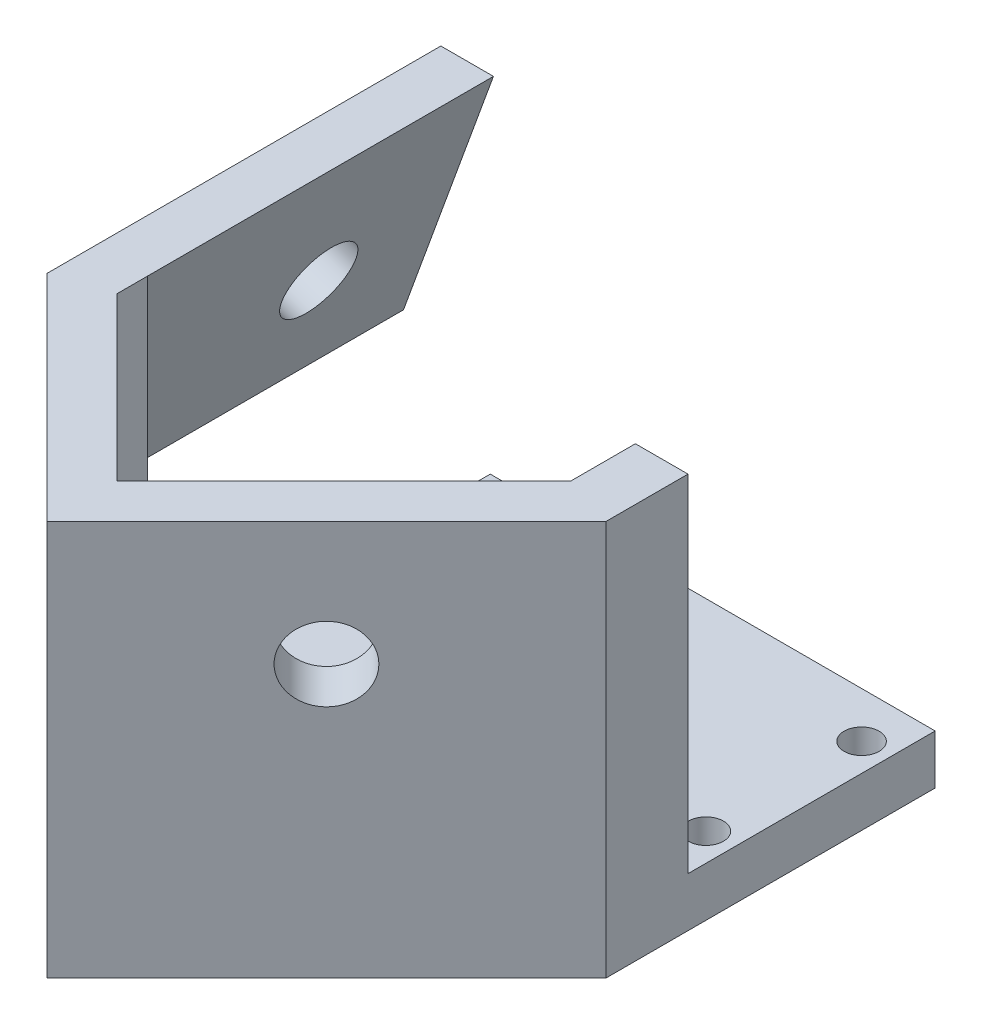
from build123d import *

# Parameters (mm, degrees)
BOSS_EXTRUDE1_DEPTH             = 15.875
SKETCH2_R                       = 4.7625
CUT_EXTRUDE1_DEPTH              = 8
SKETCH3_R                       = 4.7625
CUT_EXTRUDE2_DEPTH              = 8
CUT_EXTRUDE3_DEPTH              = 60.905780189
BOSS_EXTRUDE2_REACH             = 62.821
BOSS_EXTRUDE2_DIRECTION_2_DEPTH = 31.75
SKETCH6_R                       = 4.7625
CUT_EXTRUDE4_DEPTH              = 83.269033521
CUT_EXTRUDE5_DEPTH              = 31.75
BOSS_EXTRUDE4_DEPTH             = 31.75
CUT_EXTRUDE6_DEPTH              = 93.319424063
BOSS_EXTRUDE5_DEPTH             = 12.7
BOSS_EXTRUDE6_DEPTH             = 6.35
CUT_EXTRUDE7_DEPTH              = 71.05833388
CUT_EXTRUDE8_REACH              = 78.805
SKETCH15_R                      = 2.25
CUT_EXTRUDE9_DEPTH              = 44.45
CUT_EXTRUDE10_DEPTH             = 12.7
SKETCH21_W                      = 12.513073453
SKETCH21_H                      = 19.05
CUT_EXTRUDE11_DEPTH             = 69.753972493


with BuildPart() as part:
    # Sketch1 → Boss-Extrude1 (new, symmetric)
    with BuildSketch(Plane(origin=(0, 0, 0), x_dir=(1, 0, 0), z_dir=(0, 1, 0))):
        Polygon((-35.921024484, 0), (0, 35.921024484), (35.921024484, 0), (0, -35.921024484), align=None)
    extrude(amount=BOSS_EXTRUDE1_DEPTH, both=True)

    # Sketch2 → Cut-Extrude1 (cut)
    with BuildSketch(Plane(origin=(17.960512242, 0, 17.960512242), x_dir=(0.7071067811865476, 0, -0.7071067811865476), z_dir=(0.7071067811865476, 0, 0.7071067811865476))):
        Circle(SKETCH2_R)
    extrude(amount=-CUT_EXTRUDE1_DEPTH, mode=Mode.SUBTRACT)

    # Sketch3 → Cut-Extrude2 (cut)
    with BuildSketch(Plane(origin=(-17.960512242, 0, 17.960512242), x_dir=(0.7071067811865472, 0, 0.7071067811865478), z_dir=(-0.7071067811865478, 0, 0.7071067811865472))):
        Circle(SKETCH3_R)
    extrude(amount=-CUT_EXTRUDE2_DEPTH, mode=Mode.SUBTRACT)

    # Sketch4 → Cut-Extrude3 (cut, through all)
    with BuildSketch(Plane(origin=(0, 15.875, 0), x_dir=(1, 0, 0), z_dir=(0, 1, 0))):
        Polygon((25.4, 10.521024484), (-25.4, 10.521024484), (0, 35.921024484), align=None)
    extrude(amount=-CUT_EXTRUDE3_DEPTH, mode=Mode.SUBTRACT)

    # Boss-Extrude2: up to this face of the body (flat: up to its plane)
    boss_extrude2_end = Plane(part.part.faces().sort_by_distance((30.660512242, 0, -5.260512242))[0])
    # Sketch5 → Boss-Extrude2 (add, up to the picked face)
    with BuildSketch(Plane(origin=(0, 0, -10.521024484), x_dir=(-1, 0, 0), z_dir=(0, 0, -1)), mode=Mode.PRIVATE) as boss_extrude2_sk1:
        Polygon((-35.921024484, 15.875), (-35.921024484, -15.875), (39.135030454, -15.875), (27.578975516, 15.875), align=None)
    boss_extrude2_tool1 = split(extrude(boss_extrude2_sk1.sketch, amount=-BOSS_EXTRUDE2_REACH, mode=Mode.PRIVATE), bisect_by=boss_extrude2_end, keep=Keep.BOTH, mode=Mode.PRIVATE)
    add(boss_extrude2_tool1.solids().sort_by(Axis((1.201693, -0.441343, -10.521024), (0, 0, 1)))[0])

    # Sketch5 → Boss-Extrude2 direction 2 (add)
    with BuildSketch(Plane(origin=(0, 0, -10.521024484), x_dir=(-1, 0, 0), z_dir=(0, 0, -1))):
        Polygon((-35.921024484, 15.875), (-35.921024484, -15.875), (39.135030454, -15.875), (27.578975516, 15.875), align=None)
    extrude(amount=BOSS_EXTRUDE2_DIRECTION_2_DEPTH)

    # Sketch6 → Cut-Extrude4 (cut, through all)
    with BuildSketch(Plane(origin=(-29.45497488, 10.720734107, 0), x_dir=(0, 0, 1), z_dir=(-0.9396926207859072, 0.3420201433256724, 0))):
        with Locations(Location((-26.396024484, -11.408766942, 0), (0, 0, 270))):
            Circle(SKETCH6_R)
    extrude(amount=-CUT_EXTRUDE4_DEPTH, mode=Mode.SUBTRACT)

    # Sketch7 → Cut-Extrude5 (cut)
    with BuildSketch(Plane(origin=(0, 0, -42.271024484), x_dir=(-1, 0, 0), z_dir=(0, 0, -1))):
        Polygon((20.821446661, 15.875), (32.377501598, -15.875), (-35.921024484, -15.875), (-35.921024484, 15.875), align=None)
    extrude(amount=-CUT_EXTRUDE5_DEPTH, mode=Mode.SUBTRACT)

    # Sketch9 → Boss-Extrude4 (add)
    with BuildSketch(Plane.XZ.offset(15.875)):
        Polygon((-25.4, -10.521024484), (-35.921024484, 0), (-46.442048969, -10.521024484), align=None)
    extrude(amount=-BOSS_EXTRUDE4_DEPTH)

    # Sketch10 → Cut-Extrude6 (cut, through all)
    with BuildSketch(Plane(origin=(0, 0, -42.271024484), x_dir=(-1, 0, 0), z_dir=(0, 0, -1))):
        Polygon((46.442048969, -15.875), (46.442048969, 15.875), (27.578975516, 15.875), (39.135030454, -15.875), align=None)
    extrude(amount=-CUT_EXTRUDE6_DEPTH, mode=Mode.SUBTRACT)

    # Sketch11 → Boss-Extrude5 (add)
    with BuildSketch(Plane.XZ.offset(15.875)):
        Polygon((-32.377501598, -10.521024484), (-39.135030454, -10.521024484), (-39.135030454, -3.214005969), (0, 35.921024484), (35.921024484, 0), (35.921024484, -10.521024484), align=None)
    extrude(amount=BOSS_EXTRUDE5_DEPTH)

    # Sketch12 → Boss-Extrude6 (add)
    with BuildSketch(Plane.XZ.offset(28.575)):
        Polygon((35.921024484, -10.521024484), (35.921024484, 0), (0, 35.921024484), (-39.135030454, -3.214005969), (-39.135030454, -42.271024484), (35.921024484, -42.271024484), align=None)
    extrude(amount=BOSS_EXTRUDE6_DEPTH)

    # Sketch14 → Cut-Extrude7 (cut, through all)
    with BuildSketch(Plane(origin=(0, 0, -10.521024484), x_dir=(-1, 0, 0), z_dir=(0, 0, -1))):
        Polygon((36.999923574, -28.575), (20.821446661, 15.875), (5.050498603, 15.875), (21.228975516, -28.575), (21.228975516, -34.925), (39.135030454, -34.925), (39.135030454, -28.575), align=None)
    extrude(amount=CUT_EXTRUDE7_DEPTH, mode=Mode.SUBTRACT)

    # Sketch15 → Cut-Extrude8 (cut, up to next)
    with BuildSketch(Plane.XZ.offset(34.925), mode=Mode.PRIVATE) as cut_extrude8_sk1:
        with Locations(Location((32.346024484, -36.396024484, 0), (0, 0, 270))):
            Circle(SKETCH15_R)
    cut_extrude8_tool1 = extrude(cut_extrude8_sk1.sketch, amount=-CUT_EXTRUDE8_REACH, mode=Mode.PRIVATE) & part.part
    # Sketch15 → Cut-Extrude8 (cut, up to next)
    with BuildSketch(Plane.XZ.offset(34.925), mode=Mode.PRIVATE) as cut_extrude8_sk2:
        with Locations(Location((32.346024484, -16.396024484, 0), (0, 0, 270))):
            Circle(SKETCH15_R)
    cut_extrude8_tool2 = extrude(cut_extrude8_sk2.sketch, amount=-CUT_EXTRUDE8_REACH, mode=Mode.PRIVATE) & part.part
    # Sketch15 → Cut-Extrude8 (cut, up to next)
    with BuildSketch(Plane.XZ.offset(34.925), mode=Mode.PRIVATE) as cut_extrude8_sk3:
        with Locations(Location((-17.653975516, -16.396024484, 0), (0, 0, 270))):
            Circle(SKETCH15_R)
    cut_extrude8_tool3 = extrude(cut_extrude8_sk3.sketch, amount=-CUT_EXTRUDE8_REACH, mode=Mode.PRIVATE) & part.part
    # Sketch15 → Cut-Extrude8 (cut, up to next)
    with BuildSketch(Plane.XZ.offset(34.925), mode=Mode.PRIVATE) as cut_extrude8_sk4:
        with Locations(Location((-17.653975516, -36.396024484, 0), (0, 0, 270))):
            Circle(SKETCH15_R)
    cut_extrude8_tool4 = extrude(cut_extrude8_sk4.sketch, amount=-CUT_EXTRUDE8_REACH, mode=Mode.PRIVATE) & part.part
    add(cut_extrude8_tool1.solids().sort_by_distance((32.346024, -34.925, -36.396024))[0], mode=Mode.SUBTRACT)
    add(cut_extrude8_tool2.solids().sort_by_distance((32.346024, -34.925, -16.396024))[0], mode=Mode.SUBTRACT)
    add(cut_extrude8_tool3.solids().sort_by_distance((-17.653976, -34.925, -16.396024))[0], mode=Mode.SUBTRACT)
    add(cut_extrude8_tool4.solids().sort_by_distance((-17.653976, -34.925, -36.396024))[0], mode=Mode.SUBTRACT)

    # Sketch17 → Cut-Extrude9 (cut)
    with BuildSketch(Plane(origin=(0, 15.875, 0), x_dir=(1, 0, 0), z_dir=(0, 1, 0))):
        Polygon((-20.821446661, 10.521024484), (-20.821446661, -6.119321703), (0, -26.940768363), (29.163495629, 2.222727266), (29.163495629, 10.521024484), align=None)
    extrude(amount=-CUT_EXTRUDE9_DEPTH, mode=Mode.SUBTRACT)

    # Sketch20 → Cut-Extrude10 (cut)
    with BuildSketch(Plane(origin=(0, 0, -10.521024484), x_dir=(-1, 0, 0), z_dir=(0, 0, -1))):
        Polygon((21.228975516, -28.575), (21.228975516, -34.925), (39.135030454, -34.925), (39.135030454, -15.875), (32.377501598, -15.875), (20.821446661, 15.875), (20.821446661, -28.575), align=None)
    extrude(amount=-CUT_EXTRUDE10_DEPTH, mode=Mode.SUBTRACT)

    # Sketch21 → Cut-Extrude11 (cut, through all)
    with BuildSketch(Plane(origin=(0, 0, 2.178975516), x_dir=(-1, 0, 0), z_dir=(0, 0, -1))):
        with Locations((27.485512243, -25.4)):
            Rectangle(SKETCH21_W, SKETCH21_H)
    extrude(amount=-CUT_EXTRUDE11_DEPTH, mode=Mode.SUBTRACT)


solid = part.part
